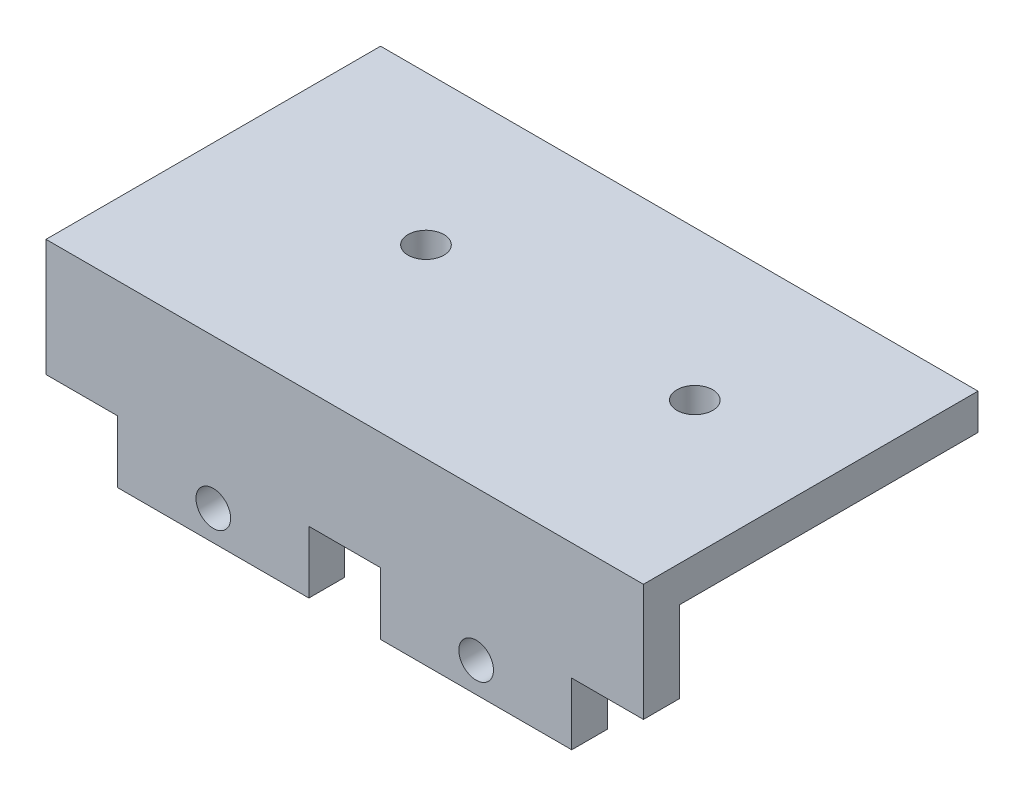
from build123d import *

# Parameters (mm, degrees)
SKETCH1_W                = 50
SKETCH1_H                = 25
SKETCH1_R                = 1.3
SKETCH1_R_2              = 4.5
BOSS_EXTRUDE1_DEPTH      = 2.5
SKETCH2_W                = 50
SKETCH2_H                = 12
BOSS_EXTRUDE2_DEPTH      = 3
SKETCH3_W                = 50
SKETCH3_H                = 28
BOSS_EXTRUDE3_DEPTH      = 3
SKETCH4_R                = 1.3
CUT_EXTRUDE1_DEPTH       = 16
SKETCH5_W                = 53
SKETCH5_H                = 32.5
SKETCH5_R                = 1.6
SKETCH5_W_2              = 42
SKETCH5_H_2              = 21.5
BOSS_EXTRUDE4_DEPTH      = 4
SKETCH7_R                = 8
CUT_EXTRUDE2_DEPTH       = 5
SKETCH8_W                = 24.55
SKETCH8_H                = 21.5
CUT_EXTRUDE3_DEPTH       = 3.8
BOSS_EXTRUDE6_DEPTH      = 22.95
BOSS_EXTRUDE7_DEPTH      = 2
SKETCH11_R               = 1.6
CUT_EXTRUDE4_DEPTH       = 1.2
SKETCH12_W               = 7
SKETCH12_H               = 21
SKETCH12_R               = 1.6
BOSS_EXTRUDE8_DEPTH      = 7.8
SKETCH13_W               = 0.7
SKETCH13_H               = 5
SKETCH13_H_2             = 4
CUT_EXTRUDE5_DEPTH       = 51
CUT_EXTRUDE5_DEPTH_BACK  = 25.95
SKETCH14_W               = 3
SKETCH14_H               = 4
SKETCH14_W_2             = 25
SKETCH14_H_2             = 5
CUT_EXTRUDE6_DEPTH       = 1
CUT_EXTRUDE6_DEPTH_BACK  = 75.95
SKETCH15_W               = 24.95
SKETCH15_H               = 3
CUT_EXTRUDE7_DEPTH       = 11
CUT_EXTRUDE7_DEPTH_BACK  = 6
SKETCH16_R               = 1.45
SKETCH16_W               = 6
SKETCH16_H               = 5.2
CUT_EXTRUDE8_DEPTH       = 1
CUT_EXTRUDE8_DEPTH_BACK  = 29
SKETCH18_R               = 1.5
CUT_EXTRUDE9_DEPTH       = 1
CUT_EXTRUDE9_DEPTH_BACK  = 16
SKETCH19_R               = 1.3
BOSS_EXTRUDE9_DEPTH      = 3
SKETCH20_R               = 1.5
CUT_EXTRUDE10_DEPTH      = 1
CUT_EXTRUDE10_DEPTH_BACK = 16


with BuildPart() as part:
    # Sketch1 → Boss-Extrude1 (new body, symmetric)
    with BuildSketch(Plane(origin=(0, 0, 0), x_dir=(1, 0, 0), z_dir=(0, 1, 0))):
        Rectangle(SKETCH1_W, SKETCH1_H)
        with Locations((-11.25, 0)):
            Circle(SKETCH1_R, mode=Mode.SUBTRACT)
        with Locations((11.25, 0)):
            Circle(SKETCH1_R_2, mode=Mode.SUBTRACT)
    extrude(amount=BOSS_EXTRUDE1_DEPTH, both=True)

    # Sketch2 → Boss-Extrude2 (add)
    with BuildSketch(Plane.XY.offset(12.5)):
        with Locations((0, 3.5)):
            Rectangle(SKETCH2_W, SKETCH2_H)
    extrude(amount=BOSS_EXTRUDE2_DEPTH)

    # Sketch3 → Boss-Extrude3 (add)
    with BuildSketch(Plane(origin=(0, 9.5, 0), x_dir=(1, 0, 0), z_dir=(0, 1, 0))):
        with Locations((0, -1.5)):
            Rectangle(SKETCH3_W, SKETCH3_H)
    extrude(amount=BOSS_EXTRUDE3_DEPTH)

    # Sketch4 → Cut-Extrude1 (cut, through all)
    with BuildSketch(Plane(origin=(0, 12.5, 0), x_dir=(1, 0, 0), z_dir=(0, 1, 0))):
        with Locations((11.25, 0)):
            Circle(SKETCH4_R)
        with Locations((-11.25, 0)):
            Circle(SKETCH4_R)
    extrude(amount=-CUT_EXTRUDE1_DEPTH, mode=Mode.SUBTRACT)

    # Sketch5 → Boss-Extrude4 (add)
    with BuildSketch(Plane.XZ.offset(2.5)):
        with Locations((21.45, -0.05)):
            Rectangle(SKETCH5_W, SKETCH5_H)
        with Locations((45.75, -5)):
            Circle(SKETCH5_R, mode=Mode.SUBTRACT)
        with Locations((45.75, 4.9)):
            Circle(SKETCH5_R, mode=Mode.SUBTRACT)
        with Locations((-2.85, 4.9)):
            Circle(SKETCH5_R, mode=Mode.SUBTRACT)
        with Locations((-2.85, -5)):
            Circle(SKETCH5_R, mode=Mode.SUBTRACT)
        with Locations((21.45, -0.05)):
            Rectangle(SKETCH5_W_2, SKETCH5_H_2, mode=Mode.SUBTRACT)
    extrude(amount=BOSS_EXTRUDE4_DEPTH)

    # Sketch7 → Cut-Extrude2 (cut)
    with BuildSketch(Plane.XZ.offset(2.5)):
        with Locations((11.25, 0)):
            Circle(SKETCH7_R)
    extrude(amount=-CUT_EXTRUDE2_DEPTH, mode=Mode.SUBTRACT)

    # Sketch8 → Cut-Extrude3 (cut)
    with BuildSketch(Plane.XZ.offset(2.5)):
        with Locations((12.725, -0.05)):
            Rectangle(SKETCH8_W, SKETCH8_H)
    extrude(amount=-CUT_EXTRUDE3_DEPTH, mode=Mode.SUBTRACT)

    # Sketch9 → Boss-Extrude6 (add)
    with BuildSketch(Plane(origin=(25, 0, 0), x_dir=(0, 0, -1), z_dir=(1, 0, 0))):
        Polygon((12.5, 2.5), (-16.2, 2.5), (-16.2, -2.5), (-10.7, -2.5), (-10.7, 1.3), (10.8, 1.3), (10.8, -2.5), (12.5, -2.5), align=None)
    extrude(amount=BOSS_EXTRUDE6_DEPTH)

    # Sketch10 → Boss-Extrude7 (add)
    with BuildSketch(Plane(origin=(47.95, 0, 0), x_dir=(0, 0, -1), z_dir=(1, 0, 0))):
        Polygon((16.3, -2.5), (12.5, -2.5), (12.5, 2.5), (-16.2, 2.5), (-16.2, -6.5), (16.3, -6.5), align=None)
    extrude(amount=BOSS_EXTRUDE7_DEPTH)

    # Sketch11 → Cut-Extrude4 (cut)
    with BuildSketch(Plane.XZ.offset(-1.3)):
        with Locations((-2.85, 4.9)):
            Circle(SKETCH11_R)
        with Locations((-2.85, -5)):
            Circle(SKETCH11_R)
        with Locations((45.75, 4.9)):
            Circle(SKETCH11_R)
        with Locations((45.75, -5)):
            Circle(SKETCH11_R)
    extrude(amount=-CUT_EXTRUDE4_DEPTH, mode=Mode.SUBTRACT)

    # Sketch12 → Boss-Extrude8 (add)
    with BuildSketch(Plane.XZ.offset(-1.3)):
        with Locations((46.45, 0.2)):
            Rectangle(SKETCH12_W, SKETCH12_H)
        with Locations((45.75, 4.9)):
            Circle(SKETCH12_R, mode=Mode.SUBTRACT)
        with Locations((45.75, -5)):
            Circle(SKETCH12_R, mode=Mode.SUBTRACT)
    extrude(amount=BOSS_EXTRUDE8_DEPTH)

    # Sketch13 → Cut-Extrude5 (cut, two sides)
    with BuildSketch(Plane.ZY.offset(-25)) as cut_extrude5_sk:
        with Locations((15.85, 0)):
            Rectangle(SKETCH13_W, SKETCH13_H)
        with Locations((15.85, -4.5)):
            Rectangle(SKETCH13_W, SKETCH13_H_2)
    extrude(amount=CUT_EXTRUDE5_DEPTH, mode=Mode.SUBTRACT)
    extrude(cut_extrude5_sk.sketch, amount=-CUT_EXTRUDE5_DEPTH_BACK, mode=Mode.SUBTRACT)

    # Sketch14 → Cut-Extrude6 (cut, two sides)
    with BuildSketch(Plane.ZY.offset(25)) as cut_extrude6_sk:
        with Locations((14, -4.5)):
            Rectangle(SKETCH14_W, SKETCH14_H)
        Polygon((-16.3, 2.5), (-16.3, -6.5), (12.5, -6.5), (12.5, -2.5), (-12.5, -2.5), (-12.5, 2.5), align=None)
        Rectangle(SKETCH14_W_2, SKETCH14_H_2)
    extrude(amount=CUT_EXTRUDE6_DEPTH, mode=Mode.SUBTRACT)
    extrude(cut_extrude6_sk.sketch, amount=-CUT_EXTRUDE6_DEPTH_BACK, mode=Mode.SUBTRACT)

    # Sketch15 → Cut-Extrude7 (cut, two sides)
    with BuildSketch(Plane(origin=(0, 2.5, 0), x_dir=(1, 0, 0), z_dir=(0, 1, 0))) as cut_extrude7_sk:
        with Locations((37.475, -14)):
            Rectangle(SKETCH15_W, SKETCH15_H)
    extrude(amount=CUT_EXTRUDE7_DEPTH, mode=Mode.SUBTRACT)
    extrude(cut_extrude7_sk.sketch, amount=-CUT_EXTRUDE7_DEPTH_BACK, mode=Mode.SUBTRACT)

    # Sketch16 → Cut-Extrude8 (cut, two sides)
    with BuildSketch(Plane.XY.offset(15.5)) as cut_extrude8_sk:
        with Locations((-11, 0)):
            Circle(SKETCH16_R)
        with Locations((11, 0)):
            Circle(SKETCH16_R)
        with Locations((-22, 0.1)):
            Rectangle(SKETCH16_W, SKETCH16_H)
        with Locations((0, 0.1)):
            Rectangle(SKETCH16_W, SKETCH16_H)
        with Locations((22, 0.1)):
            Rectangle(SKETCH16_W, SKETCH16_H)
    extrude(amount=CUT_EXTRUDE8_DEPTH, mode=Mode.SUBTRACT)
    extrude(cut_extrude8_sk.sketch, amount=-CUT_EXTRUDE8_DEPTH_BACK, mode=Mode.SUBTRACT)

    # Sketch18 → Cut-Extrude9 (cut, two sides)
    with BuildSketch(Plane(origin=(0, 12.5, 0), x_dir=(1, 0, 0), z_dir=(0, 1, 0))) as cut_extrude9_sk:
        with Locations((-8.7, 0)):
            Circle(SKETCH18_R)
    extrude(amount=CUT_EXTRUDE9_DEPTH, mode=Mode.SUBTRACT)
    extrude(cut_extrude9_sk.sketch, amount=-CUT_EXTRUDE9_DEPTH_BACK, mode=Mode.SUBTRACT)

    # Sketch19 → Boss-Extrude9 (add)
    with BuildSketch(Plane(origin=(0, 12.5, 0), x_dir=(1, 0, 0), z_dir=(0, 1, 0))):
        with BuildLine():
            ThreePointArc((-10.084803922, -0.57647038), (-10.2, 0), (-10.084803922, 0.57647038))
            ThreePointArc((-10.084803922, 0.57647038), (-12.55, 0), (-10.084803922, -0.57647038))
        make_face()
        with Locations((11.25, 0)):
            Circle(SKETCH19_R)
    extrude(amount=-BOSS_EXTRUDE9_DEPTH)

    # Sketch20 → Cut-Extrude10 (cut, two sides)
    with BuildSketch(Plane(origin=(0, 12.5, 0), x_dir=(1, 0, 0), z_dir=(0, 1, 0))) as cut_extrude10_sk:
        with Locations((13.8, 0)):
            Circle(SKETCH20_R)
    extrude(amount=CUT_EXTRUDE10_DEPTH, mode=Mode.SUBTRACT)
    extrude(cut_extrude10_sk.sketch, amount=-CUT_EXTRUDE10_DEPTH_BACK, mode=Mode.SUBTRACT)


solid = part.part
